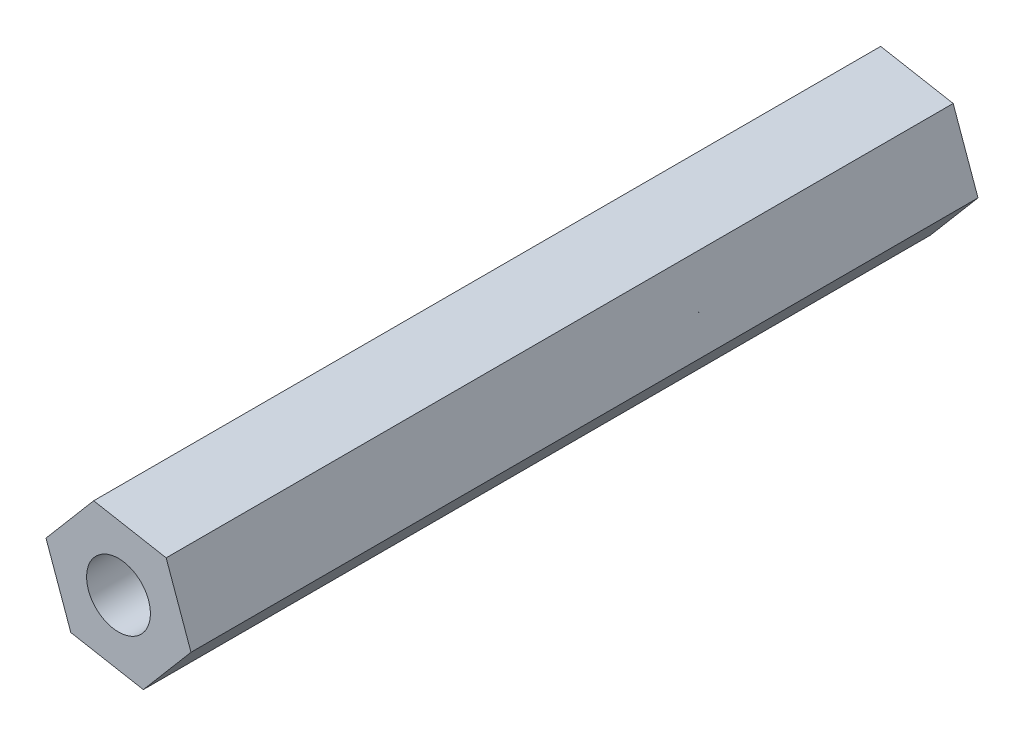
from build123d import *

# Parameters (mm, degrees)
RESSALTO_EXTRUS_O1_DEPTH = 37
ESBO_O4_R                = 1.5
CORTE_EXTRUS_O2_DEPTH    = 40


with BuildPart() as part:
    # Esboço1 → Ressalto-extrusão1 (new body)
    with BuildSketch(Plane.XY):
        Polygon((12.933175524, -4.143885809), (9.525050306, -3.523658029), (7.283854683, -6.165067156), (8.450784277, -9.426704064), (11.858909495, -10.046931845), (14.100105118, -7.405522718), align=None)
    extrude(amount=RESSALTO_EXTRUS_O1_DEPTH)

    # Esboço4 → Corte-extrusão2 (cut)
    with BuildSketch(Plane(origin=(0, 0, 0), x_dir=(-1, 0, 0), z_dir=(0, 0, -1))):
        with Locations((-10.691979901, -6.785294937)):
            Circle(ESBO_O4_R)
    extrude(amount=-CORTE_EXTRUS_O2_DEPTH, mode=Mode.SUBTRACT)


solid = part.part
